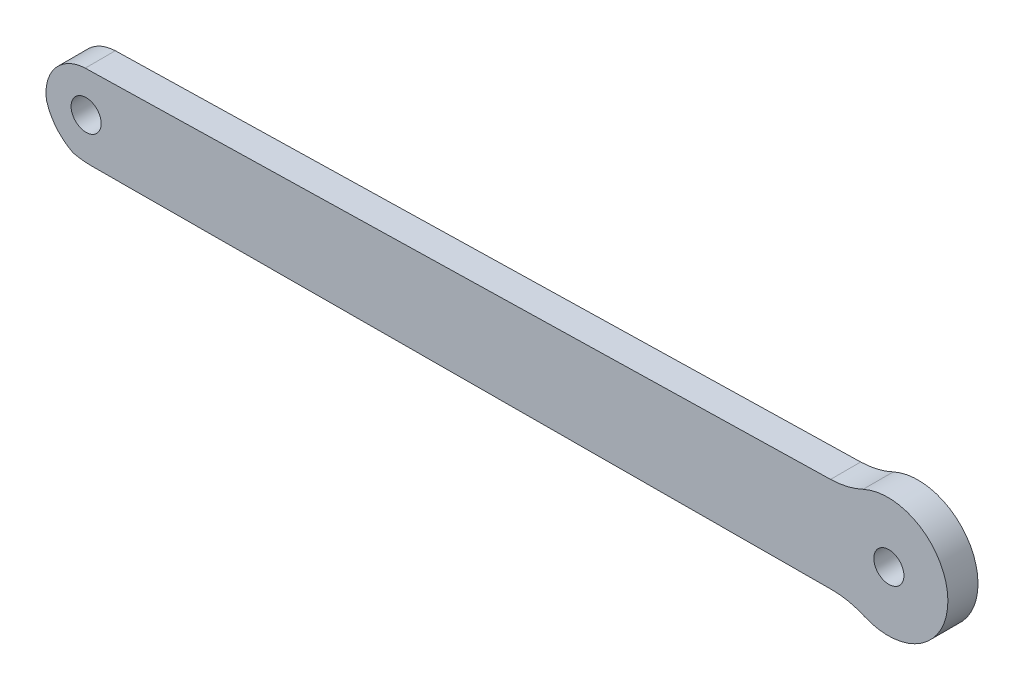
from build123d import *

# Parameters (mm, degrees)
MODEL_R             = 1.5
BOSS_EXTRUDE1_DEPTH = 3


with BuildPart() as part:
    # Model → Boss-Extrude1 (new body)
    with BuildSketch(Plane.XY):
        with BuildLine():
            Line((49.968489673, 21.049962128), (105.618768597, 21.289392046))
            ThreePointArc((105.618768597, 21.289392046), (107.285112204, 21.118249382), (108.87926509, 20.60379102))
            ThreePointArc((108.87926509, 20.60379102), (117.192196904, 26.162159278), (108.74462654, 31.51368691))
            ThreePointArc((108.74462654, 31.51368691), (107.163632348, 30.960034557), (105.502006567, 30.747729758))
            Line((105.502006567, 30.747729758), (31.227056592, 29.101105192))
            ThreePointArc((31.227056592, 29.101105192), (28.246037105, 27.617586299), (27.362873685, 24.407083556))
            ThreePointArc((27.362873685, 24.407083556), (28.356080114, 22.511229951), (30.031202973, 21.179057549))
            ThreePointArc((30.031202973, 21.179057549), (30.946620491, 21.021963969), (31.874075806, 20.972021358))
            Line((31.874075806, 20.972021358), (49.968489673, 21.049962128))
        make_face()
        with Locations((31.31571206, 25.102087789)):
            Circle(MODEL_R, mode=Mode.SUBTRACT)
        with Locations((111.309575273, 26.089603674)):
            Circle(MODEL_R, mode=Mode.SUBTRACT)
    extrude(amount=BOSS_EXTRUDE1_DEPTH)


solid = part.part
